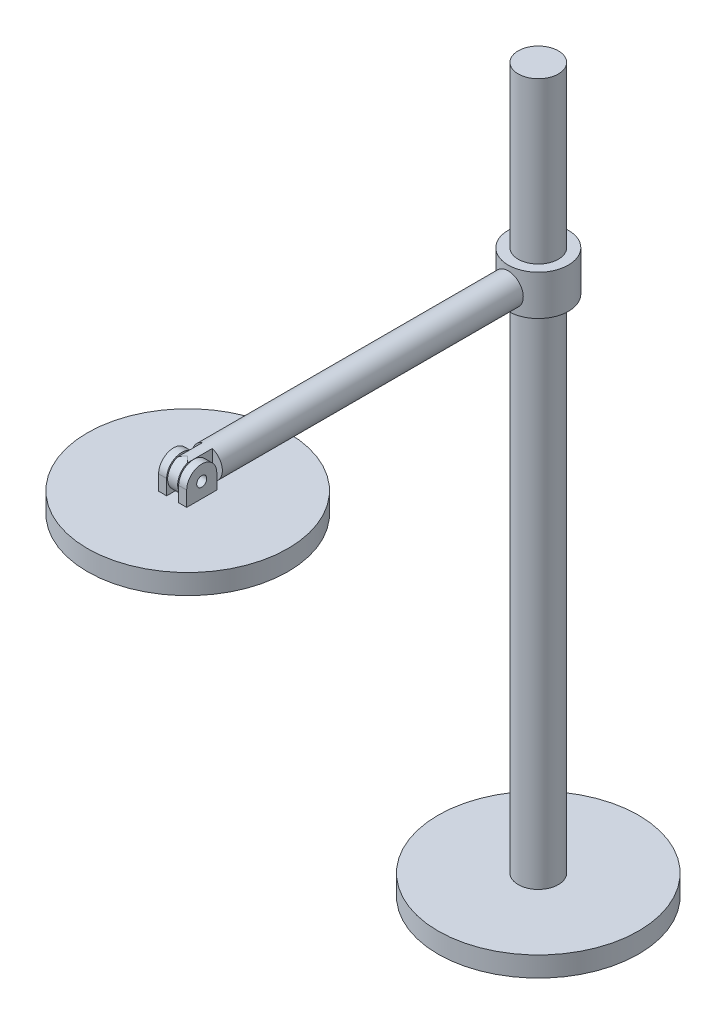
from build123d import *

# Parameters (mm, degrees)
SKETCH1_R           = 50
BOSS_EXTRUDE1_DEPTH = 10
SKETCH2_R           = 10
BOSS_EXTRUDE2_DEPTH = 350
SKETCH3_R           = 15
SKETCH3_R_2         = 10
BOSS_EXTRUDE3_DEPTH = 20
SKETCH4_R           = 7.5
BOSS_EXTRUDE4_DEPTH = 150
SKETCH5_R           = 2.5
BOSS_EXTRUDE5_DEPTH = 2.5
SKETCH6_R           = 48.158444965
CUT_EXTRUDE1_DEPTH  = 15
BOSS_EXTRUDE6_START = 3
SKETCH5_3_R         = 2.5
BOSS_EXTRUDE6_DEPTH = 4
BOSS_EXTRUDE7_START = -3
SKETCH5_4_R         = 2.5
BOSS_EXTRUDE7_DEPTH = 4
SKETCH7_R           = 40
CUT_EXTRUDE2_DEPTH  = 2


with BuildPart() as part:
    # Sketch1 → Boss-Extrude1 (new body)
    with BuildSketch(Plane(origin=(0, 0, 0), x_dir=(1, 0, 0), z_dir=(0, 1, 0))):
        Circle(SKETCH1_R)
    extrude(amount=BOSS_EXTRUDE1_DEPTH)

    # Sketch2 → Boss-Extrude2 (add)
    with BuildSketch(Plane(origin=(0, 10, 0), x_dir=(1, 0, 0), z_dir=(0, 1, 0))):
        Circle(SKETCH2_R)
    extrude(amount=BOSS_EXTRUDE2_DEPTH)

    # Sketch3 → Boss-Extrude3 (add)
    with BuildSketch(Plane(origin=(0, 260, 0), x_dir=(1, 0, 0), z_dir=(0, 1, 0))):
        Circle(SKETCH3_R)
        Circle(SKETCH3_R_2, mode=Mode.SUBTRACT)
    extrude(amount=BOSS_EXTRUDE3_DEPTH)


with BuildPart() as body_2:
    # Sketch4 → Boss-Extrude4 (new body)
    with BuildSketch(Plane.XY.offset(15)):
        with Locations((0, 270)):
            Circle(SKETCH4_R)
    extrude(amount=BOSS_EXTRUDE4_DEPTH)

    # Sketch5 → Boss-Extrude5 (add, symmetric)
    with BuildSketch(Plane(origin=(0, 0, 0), x_dir=(0, 0, -1), z_dir=(1, 0, 0))):
        with BuildLine():
            Line((-165, 262.5), (-165, 277.5))
            Line((-165, 277.5), (-174.780705462, 277.5))
            ThreePointArc((-174.780705462, 277.5), (-182.280705462, 270), (-174.780705462, 262.5))
            Line((-174.780705462, 262.5), (-165, 262.5))
        make_face()
        with Locations((-174.780705462, 270)):
            Circle(SKETCH5_R, mode=Mode.SUBTRACT)
    extrude(amount=BOSS_EXTRUDE5_DEPTH, both=True)

    # Sketch6 → Cut-Extrude1 (cut)
    with BuildSketch(Plane.XY.offset(165)):
        with Locations((0, 270)):
            Circle(SKETCH6_R)
        with BuildLine():
            ThreePointArc((2.5, 262.928932188), (-7.5, 270), (2.5, 277.071067812))
            ThreePointArc((2.5, 277.071067812), (6.123724357, 274.330127019), (7.5, 270))
            ThreePointArc((7.5, 270), (6.123724357, 265.669872981), (2.5, 262.928932188))
        make_face(mode=Mode.SUBTRACT)
    extrude(amount=CUT_EXTRUDE1_DEPTH, mode=Mode.SUBTRACT)


with BuildPart() as body_3:
    # Sketch5_3 → Boss-Extrude6 (new body)
    with BuildSketch(Plane(origin=(0, 0, 0), x_dir=(0, 0, -1), z_dir=(1, 0, 0)).offset(BOSS_EXTRUDE6_START)):
        with BuildLine():
            ThreePointArc((-167.280705462, 270), (-174.780705462, 277.5), (-182.280705462, 270))
            Line((-182.280705462, 270), (-182.280705462, 262.5))
            Line((-182.280705462, 262.5), (-167.280705462, 262.5))
            Line((-167.280705462, 262.5), (-167.280705462, 270))
        make_face()
        with Locations((-174.780705462, 270)):
            Circle(SKETCH5_3_R, mode=Mode.SUBTRACT)
    extrude(amount=BOSS_EXTRUDE6_DEPTH)



with BuildPart() as body_4:
    # Sketch5_4 → Boss-Extrude7 (new body)
    with BuildSketch(Plane(origin=(0, 0, 0), x_dir=(0, 0, -1), z_dir=(1, 0, 0)).offset(BOSS_EXTRUDE7_START)):
        with BuildLine():
            ThreePointArc((-167.280705462, 270), (-174.780705462, 277.5), (-182.280705462, 270))
            Line((-182.280705462, 270), (-182.280705462, 262.5))
            Line((-182.280705462, 262.5), (-167.280705462, 262.5))
            Line((-167.280705462, 262.5), (-167.280705462, 270))
        make_face()
        with Locations((-174.780705462, 270)):
            Circle(SKETCH5_4_R, mode=Mode.SUBTRACT)
    extrude(amount=-BOSS_EXTRUDE7_DEPTH)


with BuildPart() as body_3_1:
    add(body_3.part)

    add(body_4.part)  # Revolve1 merges body 4
    # Sketch5_5 → Revolve1 (revolve)
    with BuildSketch(Plane(origin=(0, 0, 0), x_dir=(0, 0, -1), z_dir=(1, 0, 0))):
        Polygon((-124.780705462, 262.5), (-165, 262.5), (-167.280705462, 262.5), (-174.780705462, 262.5), (-174.780705462, 252.5), (-124.780705462, 252.5), align=None)
    revolve(axis=Axis((0, 262.5, 174.780705462), (0, -1, 0)))

    # Sketch7 → Cut-Extrude2 (cut)
    with BuildSketch(Plane.XZ.offset(-252.5)):
        with Locations((0, 174.780705462)):
            Circle(SKETCH7_R)
    extrude(amount=-CUT_EXTRUDE2_DEPTH, mode=Mode.SUBTRACT)


solid = Compound([part.part, body_2.part, body_3_1.part])
